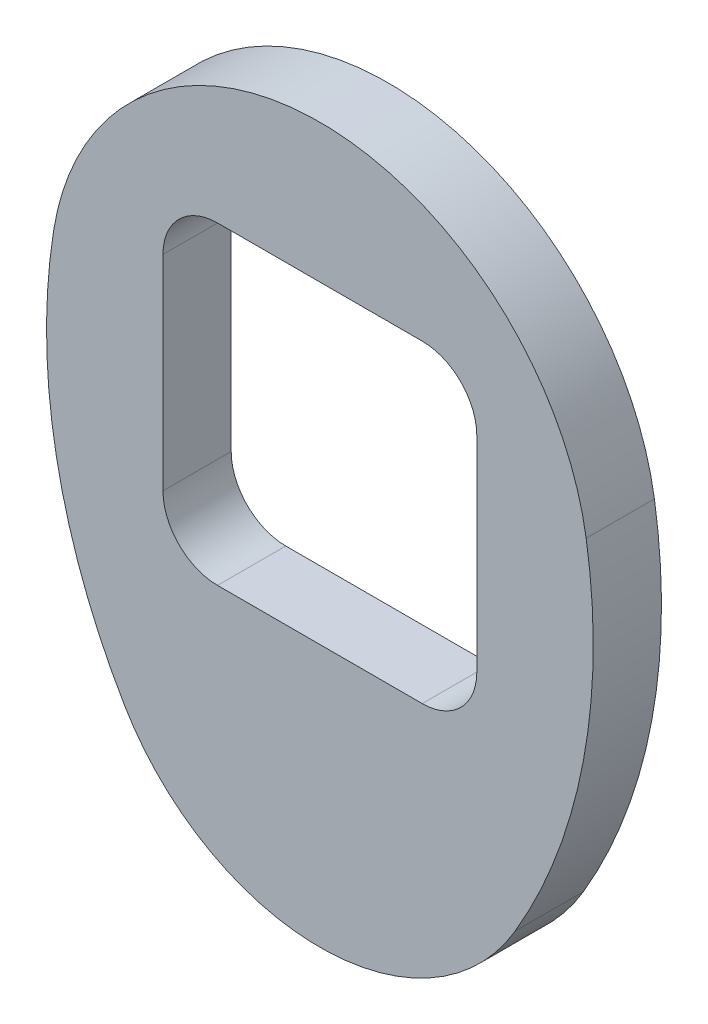
from build123d import *

# Parameters (mm, degrees)
BOSS_EXTRUDE1_DEPTH = 6.35
CUT_EXTRUDE1_REACH  = 8.35
SKETCH2_W           = 29.21
SKETCH2_H           = 29.21
FILLET1_R           = 5.08


with BuildPart() as part:
    # Sketch1 → Boss-Extrude1 (new body)
    with BuildSketch(Plane.XY):
        with BuildLine():
            ThreePointArc((-24.784009304, 31.75), (-24.524700471, 13.689081607), (-18.172986801, -3.220080042))
            ThreePointArc((-18.172986801, -3.220080042), (0, -13.612941591), (18.172986801, -3.220080042))
            ThreePointArc((18.172986801, -3.220080042), (24.524700471, 13.689081607), (24.784009304, 31.75))
            ThreePointArc((24.784009304, 31.75), (0, 52.895043223), (-24.784009304, 31.75))
        make_face()
    extrude(amount=BOSS_EXTRUDE1_DEPTH)

    # Sketch2 → Cut-Extrude1 (cut, up to next)
    with BuildSketch(Plane.XY.offset(6.35), mode=Mode.PRIVATE) as cut_extrude1_sk1:
        with Locations((0, 25.4)):
            Rectangle(SKETCH2_W, SKETCH2_H)
    cut_extrude1_tool1 = extrude(cut_extrude1_sk1.sketch, amount=-CUT_EXTRUDE1_REACH, mode=Mode.PRIVATE) & part.part
    add(cut_extrude1_tool1.solids().sort_by_distance((0, 25.4, 6.35))[0], mode=Mode.SUBTRACT)

    # Fillet1
    fillet1_edges = [part.edges().sort_by_distance(p)[0] for p in [
        (14.605, 40.005, 3.175),
        (14.605, 10.795, 3.175),
        (-14.605, 10.795, 3.175),
        (-14.605, 40.005, 3.175),
    ]]
    fillet(fillet1_edges, radius=FILLET1_R)


solid = part.part
